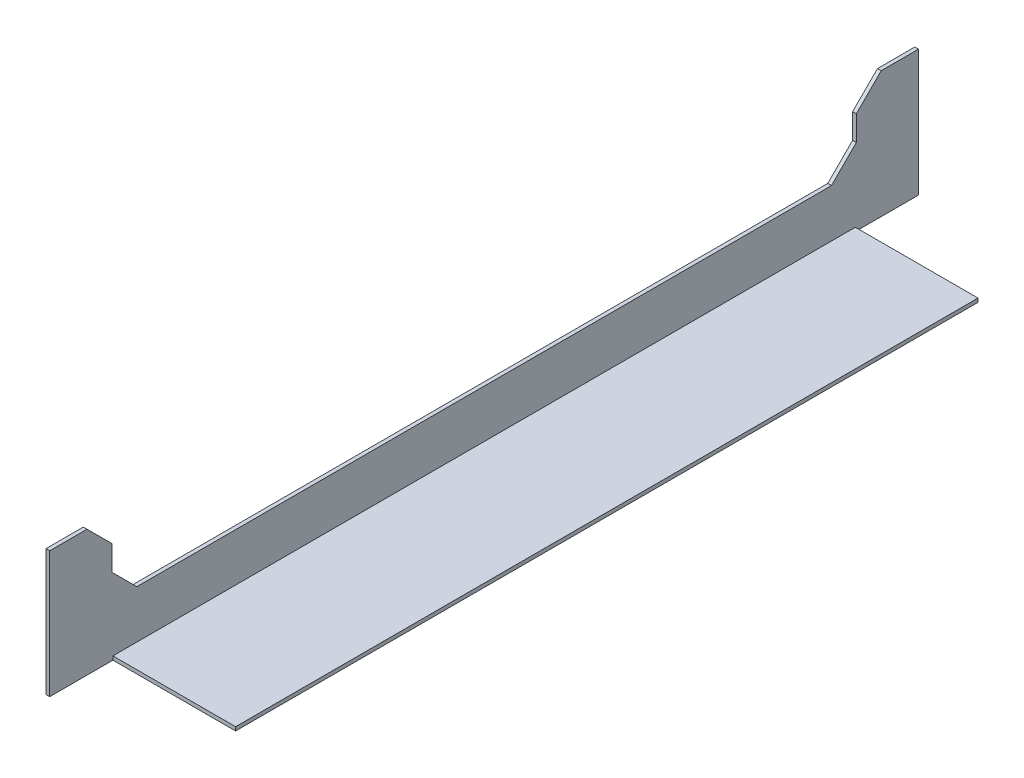
from build123d import *

# Parameters (mm, degrees)
SALIENTE_EXTRUIR1_DEPTH = 349.2
CROQUIS2_R              = 4
CORTAR_EXTRUIR1_DEPTH   = 2
CROQUIS4_W              = 49.3
CROQUIS4_H              = 25.4
CORTAR_EXTRUIR2_DEPTH   = 2
CROQUIS5_W              = 299.2
CROQUIS5_H              = 30
CORTAR_EXTRUIR3_DEPTH   = 2
CHAFL_N1_SIZE           = 10


with BuildPart() as part:
    # Croquis1 → Saliente-Extruir1 (new body)
    with BuildSketch(Plane.XY):
        Polygon((0, 0), (0, 50.8), (1.5, 50.8), (1.5, 1.5), (50.8, 1.5), (50.8, 0), align=None)
    extrude(amount=SALIENTE_EXTRUIR1_DEPTH)

    # Croquis2 → Cortar-Extruir1 (cut)
    with BuildSketch(Plane.ZY):
        with Locations((126.6, 25.4)):
            Circle(CROQUIS2_R)
        with Locations((222.6, 25.4)):
            Circle(CROQUIS2_R)
        with Locations((30.6, 25.4)):
            Circle(CROQUIS2_R)
        with Locations((318.6, 25.4)):
            Circle(CROQUIS2_R)
    extrude(amount=-CORTAR_EXTRUIR1_DEPTH, mode=Mode.SUBTRACT)

    # Croquis4 → Cortar-Extruir2 (cut)
    with BuildSketch(Plane(origin=(0, 1.5, 0), x_dir=(1, 0, 0), z_dir=(0, 1, 0))):
        with Locations((26.15, -12.7)):
            Rectangle(CROQUIS4_W, CROQUIS4_H)
        with Locations((26.15, -336.5)):
            Rectangle(CROQUIS4_W, CROQUIS4_H)
    extrude(amount=-CORTAR_EXTRUIR2_DEPTH, mode=Mode.SUBTRACT)

    # Croquis5 → Cortar-Extruir3 (cut)
    with BuildSketch(Plane.ZY):
        with Locations((174.6, 35.8)):
            Rectangle(CROQUIS5_W, CROQUIS5_H)
    extrude(amount=-CORTAR_EXTRUIR3_DEPTH, mode=Mode.SUBTRACT)

    # Chaflán1
    chafl_n1_edges = [part.edges().sort_by_distance(p)[0] for p in [
        (0.75, 50.8, 25),
        (0.75, 50.8, 324.2),
        (0.75, 20.8, 324.2),
        (0.75, 20.8, 25),
    ]]
    chamfer(chafl_n1_edges, length=CHAFL_N1_SIZE)


solid = part.part
